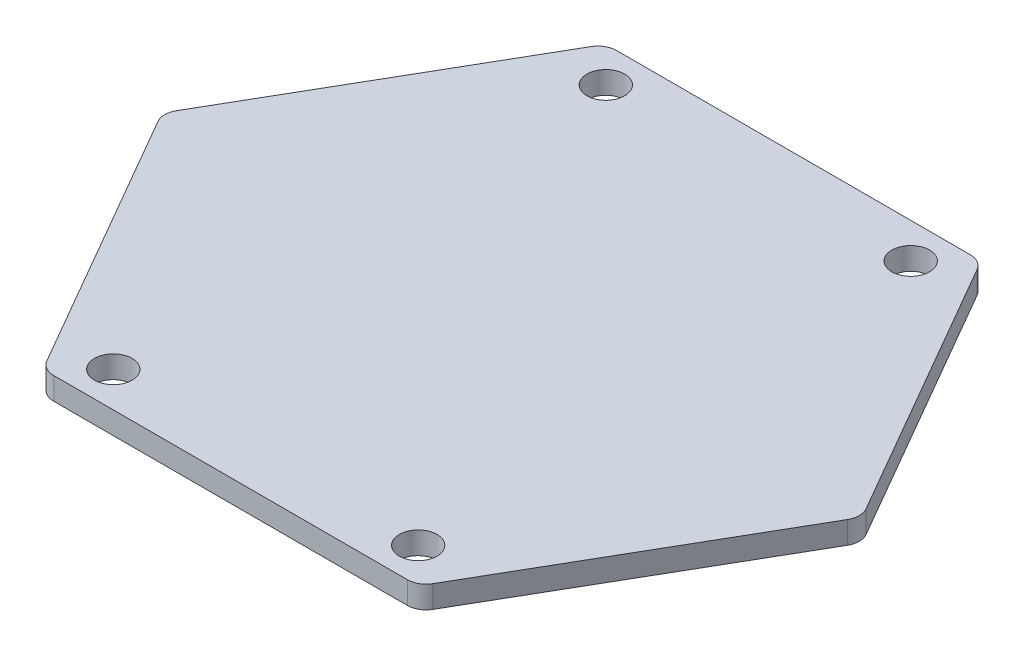
from build123d import *

# Parameters (mm, degrees)
SKETCH87_R                 = 2.5527
ACCESS_PANEL_EXTRUDE_DEPTH = 3.0226
FILLET25_R                 = 2.54


with BuildPart() as part:
    # Sketch87 → Access Panel Extrude (new body)
    with BuildSketch(Plane(origin=(0, 28.829, 0), x_dir=(1, 0, 0), z_dir=(0, 1, 0))):
        Polygon((-25.4, -66.802), (25.4, -66.802), (47.397045256, -104.902), (25.4, -143.002), (-25.4, -143.002), (-47.397045256, -104.902), align=None)
        with Locations((-20.6375, -71.5645)):
            Circle(SKETCH87_R, mode=Mode.SUBTRACT)
        with Locations((20.6375, -71.5645)):
            Circle(SKETCH87_R, mode=Mode.SUBTRACT)
        with Locations((-20.6375, -138.2395)):
            Circle(SKETCH87_R, mode=Mode.SUBTRACT)
        with Locations((20.6375, -138.2395)):
            Circle(SKETCH87_R, mode=Mode.SUBTRACT)
    extrude(amount=ACCESS_PANEL_EXTRUDE_DEPTH)

    # Fillet25
    fillet25_edges = [part.edges().sort_by_distance(p)[0] for p in [
        (-47.397045256, 30.3403, 104.902),
        (-25.4, 30.3403, 66.802),
        (25.4, 30.3403, 66.802),
        (47.397045256, 30.3403, 104.902),
        (25.4, 30.3403, 143.002),
        (-25.4, 30.3403, 143.002),
    ]]
    fillet(fillet25_edges, radius=FILLET25_R)


solid = part.part
